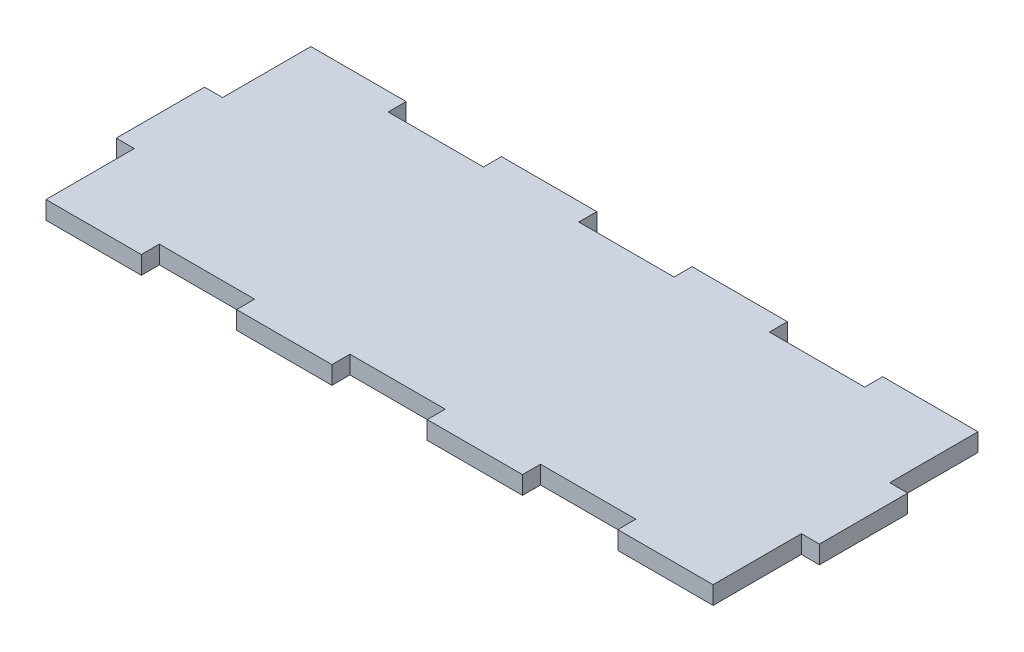
from build123d import *

# Parameters (mm, degrees)
SKETCH1_W           = 68.5
SKETCH1_H           = 23.5
BOSS_EXTRUDE1_DEPTH = 1.85
SKETCH2_W           = 9.785714286
SKETCH2_H           = 1.85
SKETCH2_W_2         = 1.85
SKETCH2_H_2         = 9.066666666
BOSS_EXTRUDE2_DEPTH = 1.85


with BuildPart() as part:
    # Sketch1 → Boss-Extrude1 (new body)
    with BuildSketch(Plane(origin=(0, 0, 0), x_dir=(1, 0, 0), z_dir=(0, 1, 0))):
        with Locations((34.25, 11.75)):
            Rectangle(SKETCH1_W, SKETCH1_H)
    extrude(amount=BOSS_EXTRUDE1_DEPTH)

    # Sketch2 → Boss-Extrude2 (add)
    with BuildSketch(Plane(origin=(0, 1.85, 0), x_dir=(1, 0, 0), z_dir=(0, 1, 0))):
        with Locations((4.892857143, -0.925)):
            Rectangle(SKETCH2_W, SKETCH2_H)
        with Locations((24.464285714, -0.925)):
            Rectangle(SKETCH2_W, SKETCH2_H)
        with Locations((44.035714286, -0.925)):
            Rectangle(SKETCH2_W, SKETCH2_H)
        with Locations((63.607142857, -0.925)):
            Rectangle(SKETCH2_W, SKETCH2_H)
        with Locations((-0.925, 11.75)):
            Rectangle(SKETCH2_W_2, SKETCH2_H_2)
        with Locations((63.607142857, 24.425)):
            Rectangle(SKETCH2_W, SKETCH2_H)
        with Locations((44.035714286, 24.425)):
            Rectangle(SKETCH2_W, SKETCH2_H)
        with Locations((24.464285714, 24.425)):
            Rectangle(SKETCH2_W, SKETCH2_H)
        with Locations((4.892857143, 24.425)):
            Rectangle(SKETCH2_W, SKETCH2_H)
        with Locations((69.425, 11.75)):
            Rectangle(SKETCH2_W_2, SKETCH2_H_2)
    extrude(amount=-BOSS_EXTRUDE2_DEPTH)


solid = part.part
